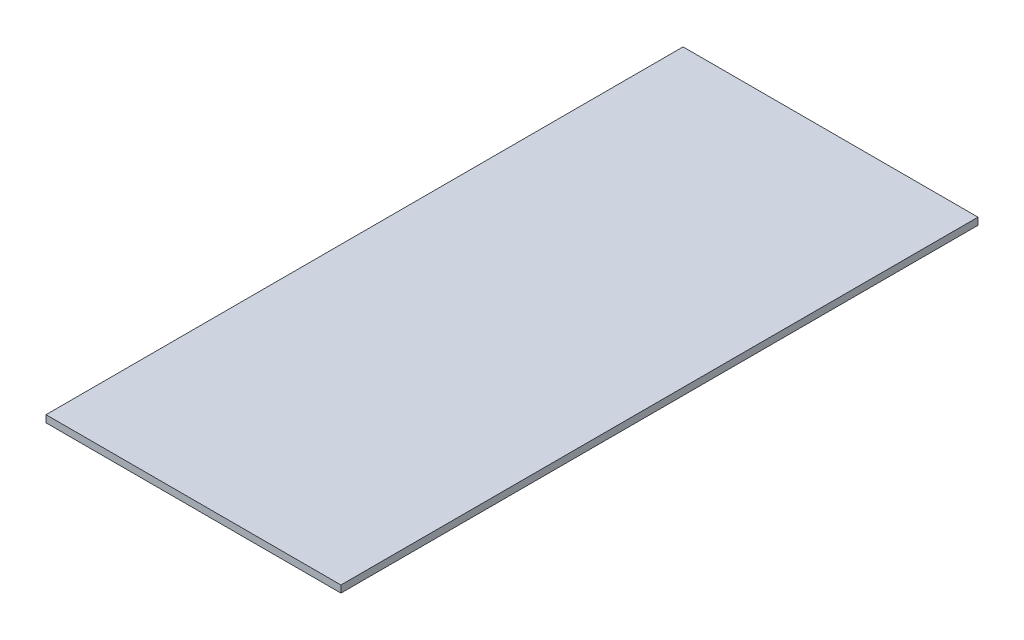
from build123d import *

# Parameters (mm, degrees)
ESQUISSE1_W        = 125
ESQUISSE1_H        = 270
BOSS_EXTRU_1_DEPTH = 3


with BuildPart() as part:
    # Esquisse1 → Boss.-Extru.1 (new body)
    with BuildSketch(Plane(origin=(0, 0, 0), x_dir=(1, 0, 0), z_dir=(0, 1, 0))):
        with Locations((62.5, 135)):
            Rectangle(ESQUISSE1_W, ESQUISSE1_H)
    extrude(amount=BOSS_EXTRU_1_DEPTH)


solid = part.part
